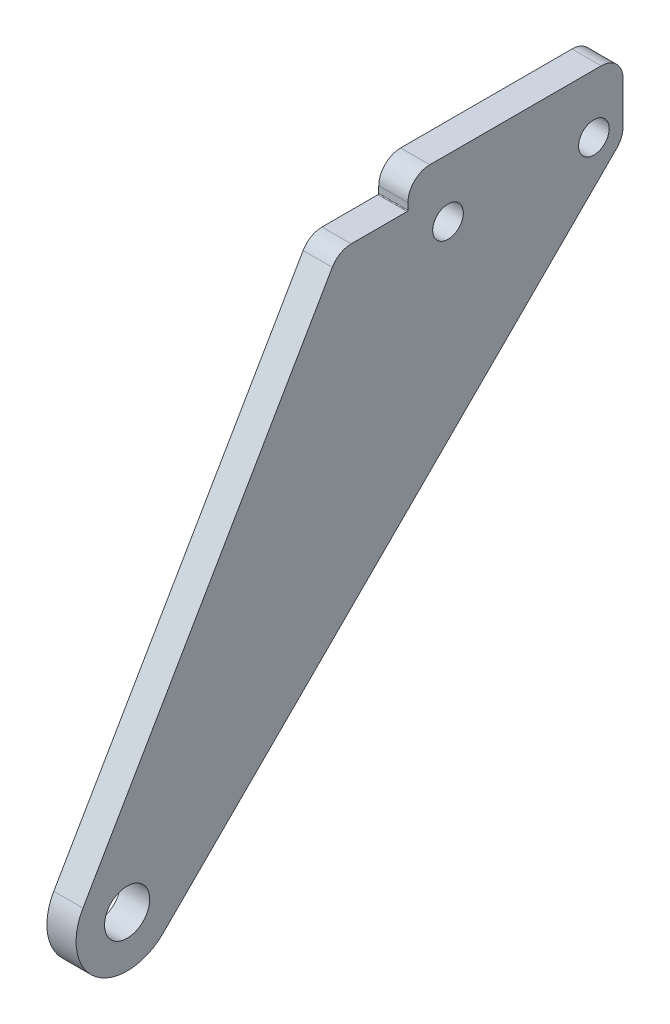
from build123d import *

# Parameters (mm, degrees)
SKETCH_1_R          = 3.1
SKETCH_1_R_2        = 2.1
EXTRUDE_1_DEPTH     = 4
SKETCH_2_W          = 35.5
SKETCH_2_H          = 4
EXTRUDE_2_DEPTH     = 4
CUT_EXTRUDE_1_DEPTH = 5
FILLET_1_R          = 3
FILLET_2_R          = 0.1


with BuildPart() as part:
    # 草图1 → 凸台-拉伸1 (new body)
    with BuildSketch(Plane(origin=(0, 0, 0), x_dir=(0, 0, -1), z_dir=(1, 0, 0))):
        with BuildLine():
            Line((-6.056426263, 3.50994315), (29, 64))
            Line((29, 64), (74, 64))
            Line((74, 64), (4.946141362, -4.95335095))
            ThreePointArc((4.946141362, -4.95335095), (-4.267905798, -5.548421406), (-6.056426263, 3.50994315))
        make_face()
        Circle(SKETCH_1_R, mode=Mode.SUBTRACT)
        with Locations((44, 60)):
            Circle(SKETCH_1_R_2, mode=Mode.SUBTRACT)
        with Locations((64, 60)):
            Circle(SKETCH_1_R_2, mode=Mode.SUBTRACT)
    extrude(amount=EXTRUDE_1_DEPTH)

    # 草图2 → 凸台-拉伸2 (add)
    with BuildSketch(Plane(origin=(4, 0, 0), x_dir=(0, 0, -1), z_dir=(1, 0, 0))):
        with Locations((56.25, 66)):
            Rectangle(SKETCH_2_W, SKETCH_2_H)
    extrude(amount=-EXTRUDE_2_DEPTH)

    # 草图3 → 切除-拉伸1 (cut, through all)
    with BuildSketch(Plane(origin=(4, 0, 0), x_dir=(0, 0, -1), z_dir=(1, 0, 0))):
        Polygon((74, 68), (68, 68), (68, 58.008732982), (74, 64), align=None)
    extrude(amount=-CUT_EXTRUDE_1_DEPTH, mode=Mode.SUBTRACT)

    # 圆角1
    fillet_1_edges = [part.edges().sort_by_distance(p)[0] for p in [
        (2, 68, -38.5),
        (2, 58.008732982, -68),
        (2, 68, -68),
        (2, 64, -29),
    ]]
    fillet(fillet_1_edges, radius=FILLET_1_R)

    # 圆角2
    fillet_2_edges = [part.edges().sort_by_distance(p)[0] for p in [
        (2, 64, -38.5),
    ]]
    fillet(fillet_2_edges, radius=FILLET_2_R)


solid = part.part
